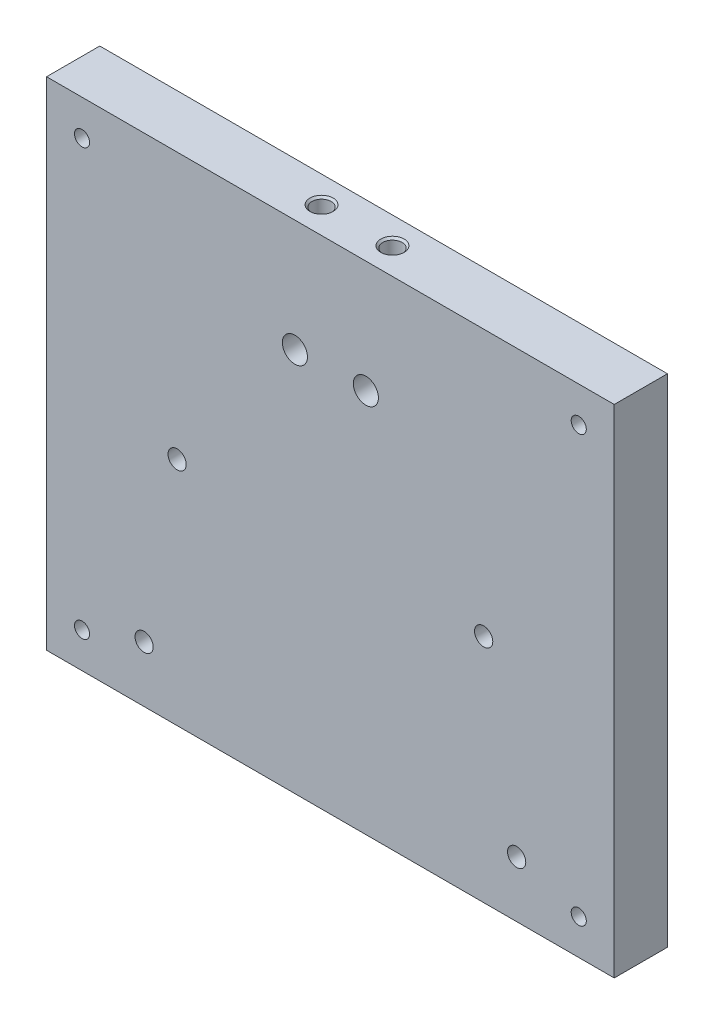
from build123d import *

# Parameters (mm, degrees)
SKETCH1_W                       = 101.6
SKETCH1_H                       = 88.9
BOSS_EXTRUDE1_DEPTH             = 9.525
F_8_32_TAPPED_HOLE1_D           = 3.4544
F_8_32_TAPPED_HOLE1_DEPTH       = 19.05
F_8_32_TAPPED_HOLE1_CSINK_D     = 4.1656
F_8_32_TAPPED_HOLE1_CSINK_ANGLE = 90
F_8_32_TAPPED_HOLE1_TIP         = 1.037806461
F_8_CLEARANCE_HOLE2_D           = 4.4958
F_8_CLEARANCE_HOLE2_DEPTH       = 25.4
F_8_CLEARANCE_HOLE2_TIP         = 1.350674586
F_6_32_TAPPED_HOLE1_D           = 2.7051
F_4_CLEARANCE_HOLE1_D           = 3.2639
F_4_CLEARANCE_HOLE1_DEPTH       = 9.525
F_4_CLEARANCE_HOLE2_D           = 3.2639
F_4_CLEARANCE_HOLE2_DEPTH       = 9.525


with BuildPart() as part:
    # Sketch1 → Boss-Extrude1 (new body)
    with BuildSketch(Plane.XY):
        with Locations((-50.8, 44.45)):
            Rectangle(SKETCH1_W, SKETCH1_H)
    extrude(amount=BOSS_EXTRUDE1_DEPTH)

    # #8-32 Tapped Hole1
    with Locations(Plane(origin=(0, 88.9, 0), x_dir=(1, 0, 0), z_dir=(0, 1, 0))):
        with Locations((-44.45, -4.7625), (-57.15, -4.7625)):
            CounterSinkHole(F_8_32_TAPPED_HOLE1_D / 2, F_8_32_TAPPED_HOLE1_CSINK_D / 2, depth=F_8_32_TAPPED_HOLE1_DEPTH, counter_sink_angle=F_8_32_TAPPED_HOLE1_CSINK_ANGLE)
            with Locations((0, 0, -(F_8_32_TAPPED_HOLE1_DEPTH + F_8_32_TAPPED_HOLE1_TIP / 2))):  # 118° drill point
                Cone(0, F_8_32_TAPPED_HOLE1_D / 2, F_8_32_TAPPED_HOLE1_TIP, mode=Mode.SUBTRACT)

    # #8 Clearance Hole2
    with Locations(Plane.XY.offset(9.525)):
        with Locations((-44.45, 68.812193539), (-57.15, 68.812193539)):
            Hole(F_8_CLEARANCE_HOLE2_D / 2, depth=F_8_CLEARANCE_HOLE2_DEPTH)
            with Locations((0, 0, -(F_8_CLEARANCE_HOLE2_DEPTH + F_8_CLEARANCE_HOLE2_TIP / 2))):  # 118° drill point
                Cone(0, F_8_CLEARANCE_HOLE2_D / 2, F_8_CLEARANCE_HOLE2_TIP, mode=Mode.SUBTRACT)

    # #6-32 Tapped Hole1 (through all)
    with Locations(Plane.XY.offset(9.525)):
        with Locations((-95.25, 6.35), (-95.25, 82.55), (-6.35, 6.35), (-6.35, 82.55)):
            Hole(F_6_32_TAPPED_HOLE1_D / 2)

    # #4 Clearance Hole1
    with Locations(Plane.XY.offset(9.525)):
        with Locations((-17.4625, 10.033), (-84.1375, 10.033)):
            Hole(F_4_CLEARANCE_HOLE1_D / 2, depth=F_4_CLEARANCE_HOLE1_DEPTH)

    # #4 Clearance Hole2
    with Locations(Plane(origin=(0, 0, 0), x_dir=(-1, 0, 0), z_dir=(0, 0, -1))):
        with Locations((23.368, 41.275), (78.232, 41.275)):
            Hole(F_4_CLEARANCE_HOLE2_D / 2, depth=F_4_CLEARANCE_HOLE2_DEPTH)


solid = part.part
